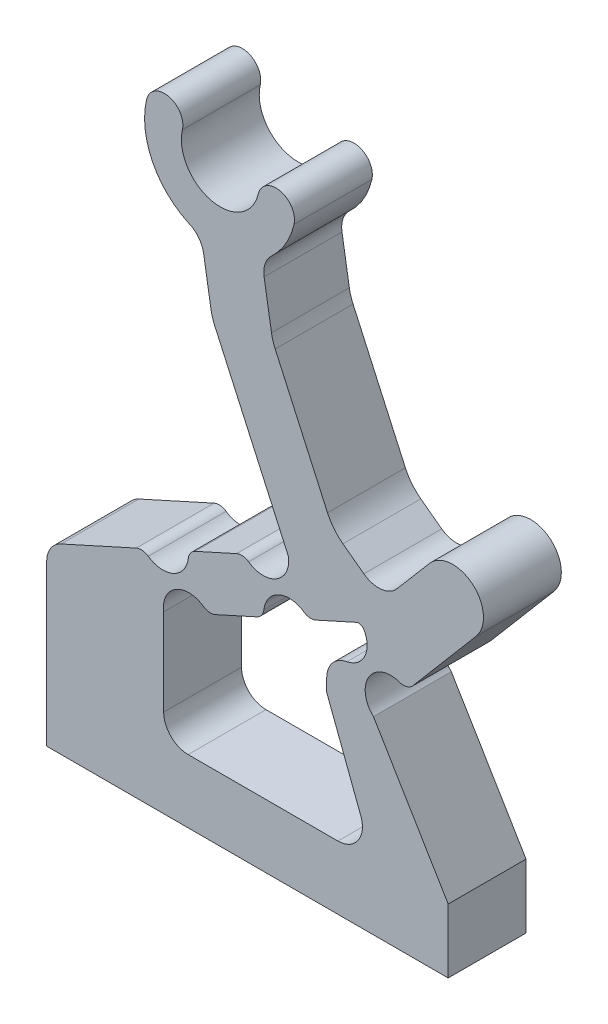
from build123d import *

# Parameters (mm, degrees)
BOSS_CONFIGUP_DEPTH = 1.5875
FILLET1_R           = 1
FILLET2_R           = 1
FILLET3_R           = 0.5
FILLET4_R           = 0.25
FILLET5_R           = 2
FILLET7_R           = 1


with BuildPart() as part:
    # Sketch-ConfigUp → Boss-ConfigUp (new body, symmetric)
    with BuildSketch(Plane.XY):
        with BuildLine():
            Line((8.036884771, -1.932633536), (5.768256233, -2.958998264))
            ThreePointArc((5.768256233, -2.958998264), (5.166306437, -4.054514783), (3.946064636, -3.783387604))
            Line((3.946064636, -3.783387604), (0, -5.568651912))
            Line((0, -5.568651912), (0, -12.738236644))
            Line((0, -12.738236644), (16.372100646, -12.738236644))
            Line((16.372100646, -12.738236644), (16.372100646, -10.126726416))
            Line((16.372100646, -10.126726416), (13.32406834, -5.02866566))
            ThreePointArc((13.32406834, -5.02866566), (13.235492103, -3.587430718), (14.672142717, -3.442382733))
            Line((14.672142717, -3.442382733), (17.513873441, -0.098510164))
            ThreePointArc((17.513873441, -0.098510164), (17.370838202, 1.663460585), (15.608867453, 1.520425346))
            Line((15.608867453, 1.520425346), (13.685572067, -0.742721767))
            Line((13.685572067, -0.742721767), (11.665230115, 0.757902988))
            Line((11.665230115, 0.757902988), (9.20945182, 6.186040346))
            Line((9.20945182, 6.186040346), (8.77136122, 8.849335746))
            ThreePointArc((8.77136122, 8.849335746), (9.609835457, 9.662661067), (10.086138806, 10.729278263))
            ThreePointArc((10.086138806, 10.729278263), (9.52657217, 11.630324976), (8.625525457, 11.07075834))
            ThreePointArc((8.625525457, 11.07075834), (6.718309914, 9.886342294), (5.533893867, 11.793557837))
            ThreePointArc((5.533893867, 11.793557837), (4.974327231, 12.69460455), (4.073280517, 12.135037914))
            ThreePointArc((4.073280517, 12.135037914), (4.437375542, 9.835058641), (6.304511976, 8.443558952))
            Line((6.304511976, 8.443558952), (6.742602576, 5.780263553))
            Line((6.742602576, 5.780263553), (9.859076368, -1.108244196))
            ThreePointArc((9.859076368, -1.108244196), (9.257126572, -2.203760715), (8.036884771, -1.932633536))
        make_face()
        with BuildLine():
            Line((8.861274111, -3.754825133), (6.592645572, -4.781189861))
            ThreePointArc((6.592645572, -4.781189861), (5.372403771, -4.510062682), (4.770453975, -5.605579201))
            Line((4.770453975, -5.605579201), (4.770453975, -10.149803039))
            Line((4.770453975, -10.149803039), (6.154904632, -10.149803039))
            Line((6.154904632, -10.149803039), (11.419062352, -10.149803039))
            Line((11.419062352, -10.149803039), (13.32406834, -10.149803039))
            Line((13.32406834, -10.149803039), (11.419062352, -5.128381701))
            Line((11.419062352, -5.128381701), (11.419062352, -3.40973015))
            ThreePointArc((11.419062352, -3.40973015), (12.78717247, -3.341145376), (12.803247984, -1.971411553))
            Line((12.803247984, -1.971411553), (10.683465708, -2.930435793))
            ThreePointArc((10.683465708, -2.930435793), (9.463223907, -2.659308614), (8.861274111, -3.754825133))
        make_face(mode=Mode.SUBTRACT)
    extrude(amount=BOSS_CONFIGUP_DEPTH, both=True)

    # Fillet1
    fillet1_edges = [part.edges().sort_by_distance(p)[0] for p in [
        (0, -5.568651912, 0),
        (6.304511976, 8.443558952, 0),
        (8.77136122, 8.849335746, 0),
        (13.685572067, -0.742721767, 0),
    ]]
    fillet(fillet1_edges, radius=FILLET1_R)

    # Fillet2
    fillet2_edges = [part.edges().sort_by_distance(p)[0] for p in [
        (11.419062352, -3.40973015, 0),
    ]]
    fillet(fillet2_edges, radius=FILLET2_R)

    # Fillet3
    fillet3_edges = [part.edges().sort_by_distance(p)[0] for p in [
        (3.946064636, -3.783387604, 0),
        (5.768256233, -2.958998264, 0),
        (8.036884771, -1.932633536, 0),
        (14.672142717, -3.442382733, 0),
        (6.592645572, -4.781189861, 0),
        (10.683465708, -2.930435793, 0),
        (8.861274111, -3.754825133, 0),
    ]]
    fillet(fillet3_edges, radius=FILLET3_R)

    # Fillet4
    fillet4_edges = [part.edges().sort_by_distance(p)[0] for p in [
        (9.859076368, -1.108244196, 0),
        (12.803247984, -1.971411553, 0),
    ]]
    fillet(fillet4_edges, radius=FILLET4_R)

    # Fillet5
    fillet5_edges = [part.edges().sort_by_distance(p)[0] for p in [
        (6.742602576, 5.780263553, 0),
        (9.20945182, 6.186040346, 0),
        (11.665230115, 0.757902988, 0),
    ]]
    fillet(fillet5_edges, radius=FILLET5_R)

    # Fillet7
    fillet7_edges = [part.edges().sort_by_distance(p)[0] for p in [
        (4.770453975, -10.149803039, 0),
        (13.32406834, -10.149803039, 0),
    ]]
    fillet(fillet7_edges, radius=FILLET7_R)


solid = part.part
